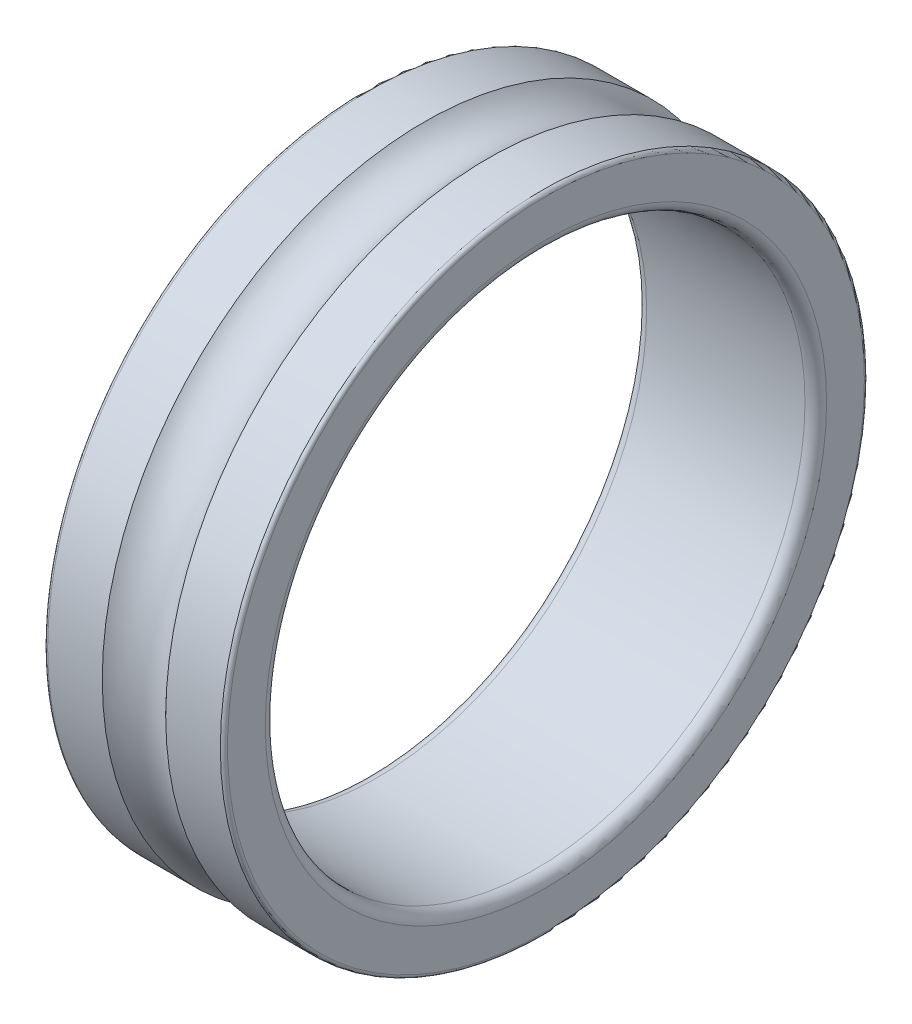
from build123d import *


with BuildPart() as part:
    # Sketch1 → Revolve1 (revolve)
    with BuildSketch(Plane.XY):
        with BuildLine():
            Line((0.3, 7.5), (4.7, 7.5))
            ThreePointArc((4.7, 7.5), (4.912132034, 7.587867966), (5, 7.8))
            Line((5, 7.8), (5, 8.85))
            ThreePointArc((5, 8.85), (4.970710678, 8.920710678), (4.9, 8.95))
            Line((4.9, 8.95), (3.381640658, 8.95))
            ThreePointArc((3.381640658, 8.95), (2.5, 8.5595), (1.618359342, 8.95))
            Line((1.618359342, 8.95), (0.1, 8.95))
            ThreePointArc((0.1, 8.95), (0.029289322, 8.920710678), (0, 8.85))
            Line((0, 8.85), (0, 7.8))
            ThreePointArc((0, 7.8), (0.087867966, 7.587867966), (0.3, 7.5))
        make_face()
    revolve(axis=Axis((4.7, 0, 0), (-1, 0, 0)))


solid = part.part
